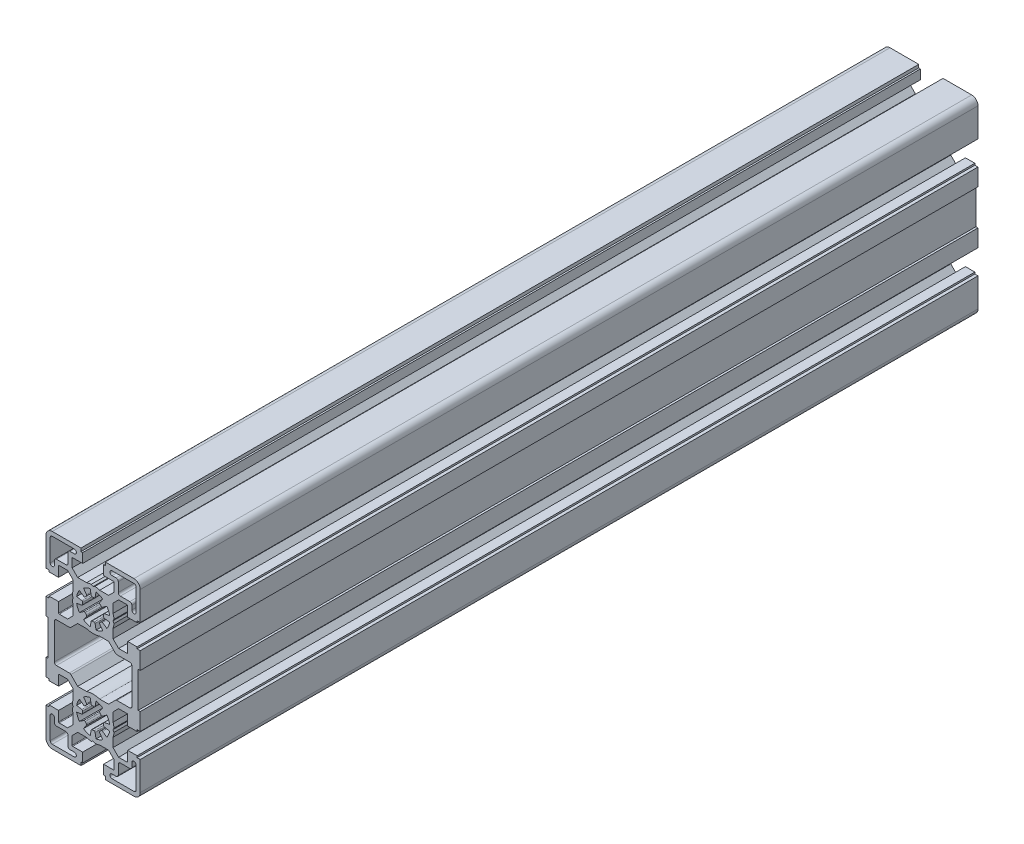
from build123d import *

# Parameters (mm, degrees)
EXTRUDE_1_DEPTH = 400


with BuildPart() as part:
    # Эскиз1 → Бобышка-Вытянуть1 (new body)
    with BuildSketch(Plane.XY):
        with BuildLine():
            Line((16.5, 27.5), (21, 27.5))
            Line((21, 27.5), (21, 28.299999))
            Line((21, 28.299999), (22.5, 28.299999))
            Line((22.5, 28.299999), (22.5, 42))
            ThreePointArc((22.5, 42), (21.621320344, 44.121320344), (19.5, 45))
            Line((19.5, 45), (5.799999, 45))
            Line((5.799999, 45), (5.799999, 43.5))
            Line((5.799999, 43.5), (5, 43.5))
            Line((5, 43.5), (5, 39))
            Line((5, 39), (9.75, 39))
            ThreePointArc((9.75, 39), (9.962132034, 38.912132034), (10.05, 38.7))
            Line((10.05, 38.7), (10.05, 34.671320344))
            Line((10.05, 34.671320344), (7.378679656, 32))
            Line((7.378679656, 32), (3.122498999, 32))
            ThreePointArc((3.122498999, 32), (2.007620973, 32.296400259), (0.866025404, 32.462429423))
            Line((0.866025404, 32.462429423), (0, 31.962429423))
            Line((0, 31.962429423), (-0.866025404, 32.462429423))
            ThreePointArc((-0.866025404, 32.462429423), (-2.007620973, 32.296400259), (-3.122498999, 32))
            Line((-3.122498999, 32), (-7.378679656, 32))
            Line((-7.378679656, 32), (-10.049999, 34.671319344))
            Line((-10.049999, 34.671319344), (-10.049999, 38.7))
            ThreePointArc((-10.049999, 38.7), (-9.962131034, 38.912132034), (-9.749999, 39))
            Line((-9.749999, 39), (-5, 39))
            Line((-5, 39), (-5, 43.5))
            Line((-5, 43.5), (-5.799999, 43.5))
            Line((-5.799999, 43.5), (-5.799999, 45))
            Line((-5.799999, 45), (-19.5, 45))
            ThreePointArc((-19.5, 45), (-21.621320344, 44.121320344), (-22.5, 42))
            Line((-22.5, 42), (-22.5, 28.299999))
            Line((-22.5, 28.299999), (-21, 28.299999))
            Line((-21, 28.299999), (-21, 27.5))
            Line((-21, 27.5), (-16.5, 27.5))
            Line((-16.5, 27.5), (-16.5, 32.249999))
            ThreePointArc((-16.5, 32.249999), (-16.412132034, 32.462131034), (-16.2, 32.549999))
            Line((-16.2, 32.549999), (-12.171319344, 32.549999))
            Line((-12.171319344, 32.549999), (-9.5, 29.878679656))
            Line((-9.5, 29.878679656), (-9.5, 25.622498999))
            ThreePointArc((-9.5, 25.622498999), (-9.796400259, 24.507620973), (-9.962429423, 23.366025404))
            Line((-9.962429423, 23.366025404), (-9.462429423, 22.5))
            Line((-9.462429423, 22.5), (-9.962429423, 21.633974596))
            ThreePointArc((-9.962429423, 21.633974596), (-9.796400259, 20.492379027), (-9.5, 19.377501001))
            Line((-9.5, 19.377501001), (-9.5, 15.121320344))
            Line((-9.5, 15.121320344), (-12.171320344, 12.45))
            Line((-12.171320344, 12.45), (-16.2, 12.45))
            ThreePointArc((-16.2, 12.45), (-16.412132034, 12.537867966), (-16.5, 12.75))
            Line((-16.5, 12.75), (-16.5, 17.5))
            Line((-16.5, 17.5), (-21, 17.5))
            Line((-21, 17.5), (-21, 16.700001))
            Line((-21, 16.700001), (-22.5, 16.700001))
            Line((-22.5, 16.700001), (-22.5, 8.5))
            Line((-22.5, 8.5), (-21.5, 8.5))
            Line((-21.5, 8.5), (-21.5, -8.5))
            Line((-21.5, -8.5), (-22.5, -8.5))
            Line((-22.5, -8.5), (-22.5, -16.700001))
            Line((-22.5, -16.700001), (-21, -16.700001))
            Line((-21, -16.700001), (-21, -17.5))
            Line((-21, -17.5), (-16.5, -17.5))
            Line((-16.5, -17.5), (-16.5, -12.75))
            ThreePointArc((-16.5, -12.75), (-16.412132034, -12.537867966), (-16.2, -12.45))
            Line((-16.2, -12.45), (-12.171320344, -12.45))
            Line((-12.171320344, -12.45), (-9.5, -15.121320344))
            Line((-9.5, -15.121320344), (-9.5, -19.377501001))
            ThreePointArc((-9.5, -19.377501001), (-9.796400259, -20.492379027), (-9.962429423, -21.633974596))
            Line((-9.962429423, -21.633974596), (-9.462429423, -22.5))
            Line((-9.462429423, -22.5), (-9.962429423, -23.366025404))
            ThreePointArc((-9.962429423, -23.366025404), (-9.796400259, -24.507620973), (-9.5, -25.622498999))
            Line((-9.5, -25.622498999), (-9.5, -29.878679656))
            Line((-9.5, -29.878679656), (-12.171319344, -32.549999))
            Line((-12.171319344, -32.549999), (-16.2, -32.549999))
            ThreePointArc((-16.2, -32.549999), (-16.412132034, -32.462131034), (-16.5, -32.249999))
            Line((-16.5, -32.249999), (-16.5, -27.5))
            Line((-16.5, -27.5), (-21, -27.5))
            Line((-21, -27.5), (-21, -28.299999))
            Line((-21, -28.299999), (-22.5, -28.299999))
            Line((-22.5, -28.299999), (-22.5, -42))
            ThreePointArc((-22.5, -42), (-21.621320344, -44.121320344), (-19.5, -45))
            Line((-19.5, -45), (-5.799999, -45))
            Line((-5.799999, -45), (-5.799999, -43.5))
            Line((-5.799999, -43.5), (-5, -43.5))
            Line((-5, -43.5), (-5, -39))
            Line((-5, -39), (-9.749999, -39))
            ThreePointArc((-9.749999, -39), (-9.962131034, -38.912132034), (-10.049999, -38.7))
            Line((-10.049999, -38.7), (-10.049999, -34.671319344))
            Line((-10.049999, -34.671319344), (-7.378679656, -32))
            Line((-7.378679656, -32), (-3.122498999, -32))
            ThreePointArc((-3.122498999, -32), (-2.007620973, -32.296400259), (-0.866025404, -32.462429423))
            Line((-0.866025404, -32.462429423), (0, -31.962429423))
            Line((0, -31.962429423), (0.866025404, -32.462429423))
            ThreePointArc((0.866025404, -32.462429423), (2.007620973, -32.296400259), (3.122498999, -32))
            Line((3.122498999, -32), (7.378679656, -32))
            Line((7.378679656, -32), (10.05, -34.671320344))
            Line((10.05, -34.671320344), (10.05, -38.7))
            ThreePointArc((10.05, -38.7), (9.962132034, -38.912132034), (9.75, -39))
            Line((9.75, -39), (5, -39))
            Line((5, -39), (5, -43.5))
            Line((5, -43.5), (5.799999, -43.5))
            Line((5.799999, -43.5), (5.799999, -45))
            Line((5.799999, -45), (19.5, -45))
            ThreePointArc((19.5, -45), (21.621320344, -44.121320344), (22.5, -42))
            Line((22.5, -42), (22.5, -28.299999))
            Line((22.5, -28.299999), (21, -28.299999))
            Line((21, -28.299999), (21, -27.5))
            Line((21, -27.5), (16.5, -27.5))
            Line((16.5, -27.5), (16.5, -32.249999))
            ThreePointArc((16.5, -32.249999), (16.412132034, -32.462131034), (16.2, -32.549999))
            Line((16.2, -32.549999), (12.171319344, -32.549999))
            Line((12.171319344, -32.549999), (9.5, -29.878679656))
            Line((9.5, -29.878679656), (9.5, -25.622498999))
            ThreePointArc((9.5, -25.622498999), (9.796400259, -24.507620973), (9.962429423, -23.366025404))
            Line((9.962429423, -23.366025404), (9.462429423, -22.5))
            Line((9.462429423, -22.5), (9.962429423, -21.633974596))
            ThreePointArc((9.962429423, -21.633974596), (9.796400259, -20.492379027), (9.5, -19.377501001))
            Line((9.5, -19.377501001), (9.5, -15.121320344))
            Line((9.5, -15.121320344), (12.171320344, -12.45))
            Line((12.171320344, -12.45), (16.2, -12.45))
            ThreePointArc((16.2, -12.45), (16.412132034, -12.537867966), (16.5, -12.75))
            Line((16.5, -12.75), (16.5, -17.5))
            Line((16.5, -17.5), (21, -17.5))
            Line((21, -17.5), (21, -16.700001))
            Line((21, -16.700001), (22.5, -16.700001))
            Line((22.5, -16.700001), (22.5, -8.5))
            Line((22.5, -8.5), (21.5, -8.5))
            Line((21.5, -8.5), (21.5, 8.5))
            Line((21.5, 8.5), (22.5, 8.5))
            Line((22.5, 8.5), (22.5, 16.700001))
            Line((22.5, 16.700001), (21, 16.700001))
            Line((21, 16.700001), (21, 17.5))
            Line((21, 17.5), (16.5, 17.5))
            Line((16.5, 17.5), (16.5, 12.75))
            ThreePointArc((16.5, 12.75), (16.412132034, 12.537867966), (16.2, 12.45))
            Line((16.2, 12.45), (12.171320344, 12.45))
            Line((12.171320344, 12.45), (9.5, 15.121320344))
            Line((9.5, 15.121320344), (9.5, 19.377501001))
            ThreePointArc((9.5, 19.377501001), (9.796400259, 20.492379027), (9.962429423, 21.633974596))
            Line((9.962429423, 21.633974596), (9.462429423, 22.5))
            Line((9.462429423, 22.5), (9.962429423, 23.366025404))
            ThreePointArc((9.962429423, 23.366025404), (9.796400259, 24.507620973), (9.5, 25.622498999))
            Line((9.5, 25.622498999), (9.5, 29.878679656))
            Line((9.5, 29.878679656), (12.171319344, 32.549999))
            Line((12.171319344, 32.549999), (16.2, 32.549999))
            ThreePointArc((16.2, 32.549999), (16.412132034, 32.462131034), (16.5, 32.249999))
            Line((16.5, 32.249999), (16.5, 27.5))
        make_face()
        with BuildLine():
            Line((-0.951109584, 27.894014463), (-1.38918508, 30.378462452))
            ThreePointArc((-1.38918508, 30.378462452), (-3.061467429, 29.891036664), (-4.588611737, 29.053216624))
            Line((-4.588611737, 29.053216624), (-3.14160736, 26.986680308))
            ThreePointArc((-3.14160736, 26.986680308), (-3.055338858, 26.635563126), (-3.228348507, 26.31808369))
            ThreePointArc((-3.228348507, 26.31808369), (-3.535533704, 26.035533704), (-3.81808369, 25.728348507))
            ThreePointArc((-3.81808369, 25.728348507), (-4.135563126, 25.555338858), (-4.486680308, 25.64160736))
            Line((-4.486680308, 25.64160736), (-6.553216624, 27.088611737))
            ThreePointArc((-6.553216624, 27.088611737), (-7.391036664, 25.561467429), (-7.878462452, 23.88918508))
            Line((-7.878462452, 23.88918508), (-5.394014463, 23.451109584))
            ThreePointArc((-5.394014463, 23.451109584), (-5.084736142, 23.263833295), (-4.982580573, 22.917005199))
            ThreePointArc((-4.982580573, 22.917005199), (-5.000000251, 22.5), (-4.982580573, 22.082994801))
            ThreePointArc((-4.982580573, 22.082994801), (-5.084736142, 21.736166705), (-5.394014463, 21.548890416))
            Line((-5.394014463, 21.548890416), (-7.878461766, 21.110815041))
            ThreePointArc((-7.878461766, 21.110815041), (-7.391036076, 19.43853297), (-6.553216219, 17.911388898))
            Line((-6.553216219, 17.911388898), (-4.486680308, 19.35839264))
            ThreePointArc((-4.486680308, 19.35839264), (-4.135563126, 19.444661142), (-3.81808369, 19.271651493))
            ThreePointArc((-3.81808369, 19.271651493), (-3.535533733, 18.964466325), (-3.22834857, 18.681916364))
            ThreePointArc((-3.22834857, 18.681916364), (-3.055338921, 18.364436882), (-3.141607485, 18.013319673))
            Line((-3.141607485, 18.013319673), (-4.588611972, 15.94678404))
            ThreePointArc((-4.588611972, 15.94678404), (-3.061467529, 15.10896382), (-1.38918499, 14.621537948))
            Line((-1.38918499, 14.621537948), (-0.951109584, 17.105985537))
            ThreePointArc((-0.951109584, 17.105985537), (-0.763833295, 17.415263858), (-0.417005199, 17.517419427))
            ThreePointArc((-0.417005199, 17.517419427), (0, 17.499999749), (0.417005199, 17.517419427))
            ThreePointArc((0.417005199, 17.517419427), (0.763833295, 17.415263858), (0.951109584, 17.105985537))
            Line((0.951109584, 17.105985537), (1.389184959, 14.621538234))
            ThreePointArc((1.389184959, 14.621538234), (3.061467283, 15.108964029), (4.58861155, 15.946784095))
            Line((4.58861155, 15.946784095), (3.141607485, 18.013319673))
            ThreePointArc((3.141607485, 18.013319673), (3.055338921, 18.364436882), (3.22834857, 18.681916364))
            ThreePointArc((3.22834857, 18.681916364), (3.535533704, 18.964466296), (3.818083636, 19.27165143))
            ThreePointArc((3.818083636, 19.27165143), (4.135563118, 19.444661079), (4.486680327, 19.358392515))
            Line((4.486680327, 19.358392515), (6.55321596, 17.911388028))
            ThreePointArc((6.55321596, 17.911388028), (7.39103618, 19.438532471), (7.878462052, 21.11081501))
            Line((7.878462052, 21.11081501), (5.394014463, 21.548890416))
            ThreePointArc((5.394014463, 21.548890416), (5.084736142, 21.736166705), (4.982580573, 22.082994801))
            ThreePointArc((4.982580573, 22.082994801), (5.000000251, 22.5), (4.982580573, 22.917005199))
            ThreePointArc((4.982580573, 22.917005199), (5.084736142, 23.263833295), (5.394014463, 23.451109584))
            Line((5.394014463, 23.451109584), (7.878462049, 23.889185009))
            ThreePointArc((7.878462049, 23.889185009), (7.391036176, 25.561467538), (6.55321596, 27.088611972))
            Line((6.55321596, 27.088611972), (4.486680327, 25.641607485))
            ThreePointArc((4.486680327, 25.641607485), (4.135563118, 25.555338921), (3.818083636, 25.72834857))
            ThreePointArc((3.818083636, 25.72834857), (3.535533675, 26.035533733), (3.228348507, 26.31808369))
            ThreePointArc((3.228348507, 26.31808369), (3.055338858, 26.635563126), (3.14160736, 26.986680308))
            Line((3.14160736, 26.986680308), (4.588611737, 29.053216624))
            ThreePointArc((4.588611737, 29.053216624), (3.061467429, 29.891036664), (1.38918508, 30.378462452))
            Line((1.38918508, 30.378462452), (0.951109584, 27.894014463))
            ThreePointArc((0.951109584, 27.894014463), (0.763833295, 27.584736142), (0.417005199, 27.482580573))
            ThreePointArc((0.417005199, 27.482580573), (0, 27.500000251), (-0.417005199, 27.482580573))
            ThreePointArc((-0.417005199, 27.482580573), (-0.763833295, 27.584736142), (-0.951109584, 27.894014463))
        make_face(mode=Mode.SUBTRACT)
        with BuildLine():
            Line((-17.5, 34.5), (-13, 34.5))
            ThreePointArc((-13, 34.5), (-12.292894344, 34.792894094), (-12.000002, 35.500000474))
            Line((-12.000002, 35.500000474), (-12, 40))
            ThreePointArc((-12, 40), (-11.707106781, 40.707106781), (-11, 41))
            Line((-11, 41), (-9, 41))
            ThreePointArc((-9, 41), (-8, 42), (-9, 43))
            Line((-9, 43), (-19.5, 43))
            ThreePointArc((-19.5, 43), (-20.207106781, 42.707106781), (-20.5, 42))
            Line((-20.5, 42), (-20.5, 31.5))
            ThreePointArc((-20.5, 31.5), (-19.5, 30.5), (-18.5, 31.5))
            Line((-18.5, 31.5), (-18.5, 33.5))
            ThreePointArc((-18.5, 33.5), (-18.207106781, 34.207106781), (-17.5, 34.5))
        make_face(mode=Mode.SUBTRACT)
        with BuildLine():
            Line((-7.378679656, 13), (-3.122498999, 13))
            ThreePointArc((-3.122498999, 13), (0, 12.5), (3.122498999, 13))
            Line((3.122498999, 13), (7.378679656, 13))
            Line((7.378679656, 13), (10.635786438, 9.742893219))
            ThreePointArc((10.635786438, 9.742893219), (10.960209786, 9.526120467), (11.342893219, 9.45))
            Line((11.342893219, 9.45), (17.5, 9.45))
            ThreePointArc((17.5, 9.45), (18.207106781, 9.157106781), (18.5, 8.45))
            Line((18.5, 8.45), (18.5, -8.45))
            ThreePointArc((18.5, -8.45), (18.207106781, -9.157106781), (17.5, -9.45))
            Line((17.5, -9.45), (11.342893219, -9.45))
            ThreePointArc((11.342893219, -9.45), (10.960209786, -9.526120467), (10.635786438, -9.742893219))
            Line((10.635786438, -9.742893219), (7.378679656, -13))
            Line((7.378679656, -13), (3.122498999, -13))
            ThreePointArc((3.122498999, -13), (0, -12.5), (-3.122498999, -13))
            Line((-3.122498999, -13), (-7.378679656, -13))
            Line((-7.378679656, -13), (-10.635786438, -9.742893219))
            ThreePointArc((-10.635786438, -9.742893219), (-10.960209786, -9.526120467), (-11.342893219, -9.45))
            Line((-11.342893219, -9.45), (-17.5, -9.45))
            ThreePointArc((-17.5, -9.45), (-18.207106781, -9.157106781), (-18.5, -8.45))
            Line((-18.5, -8.45), (-18.5, 8.45))
            ThreePointArc((-18.5, 8.45), (-18.207106781, 9.157106781), (-17.5, 9.45))
            Line((-17.5, 9.45), (-11.342893219, 9.45))
            ThreePointArc((-11.342893219, 9.45), (-10.960209786, 9.526120467), (-10.635786438, 9.742893219))
            Line((-10.635786438, 9.742893219), (-7.378679656, 13))
        make_face(mode=Mode.SUBTRACT)
        with BuildLine():
            Line((17.5, 34.5), (13.000000474, 34.500002))
            ThreePointArc((13.000000474, 34.500002), (12.292894094, 34.792894344), (12, 35.5))
            Line((12, 35.5), (12, 40))
            ThreePointArc((12, 40), (11.707106781, 40.707106781), (11, 41))
            Line((11, 41), (9, 41))
            ThreePointArc((9, 41), (8, 42), (9, 43))
            Line((9, 43), (19.5, 43))
            ThreePointArc((19.5, 43), (20.207106781, 42.707106781), (20.5, 42))
            Line((20.5, 42), (20.5, 31.5))
            ThreePointArc((20.5, 31.5), (19.5, 30.5), (18.5, 31.5))
            Line((18.5, 31.5), (18.5, 33.5))
            ThreePointArc((18.5, 33.5), (18.207106781, 34.207106781), (17.5, 34.5))
        make_face(mode=Mode.SUBTRACT)
        with BuildLine():
            Line((-0.951109584, -27.894014463), (-1.38918508, -30.378462452))
            ThreePointArc((-1.38918508, -30.378462452), (-3.061467429, -29.891036664), (-4.588611737, -29.053216624))
            Line((-4.588611737, -29.053216624), (-3.14160736, -26.986680308))
            ThreePointArc((-3.14160736, -26.986680308), (-3.055338858, -26.635563126), (-3.228348507, -26.31808369))
            ThreePointArc((-3.228348507, -26.31808369), (-3.535533704, -26.035533704), (-3.81808369, -25.728348507))
            ThreePointArc((-3.81808369, -25.728348507), (-4.135563126, -25.555338858), (-4.486680308, -25.64160736))
            Line((-4.486680308, -25.64160736), (-6.553216624, -27.088611737))
            ThreePointArc((-6.553216624, -27.088611737), (-7.391036664, -25.561467429), (-7.878462452, -23.88918508))
            Line((-7.878462452, -23.88918508), (-5.394014463, -23.451109584))
            ThreePointArc((-5.394014463, -23.451109584), (-5.084736142, -23.263833295), (-4.982580573, -22.917005199))
            ThreePointArc((-4.982580573, -22.917005199), (-5.000000251, -22.5), (-4.982580573, -22.082994801))
            ThreePointArc((-4.982580573, -22.082994801), (-5.084736142, -21.736166705), (-5.394014463, -21.548890416))
            Line((-5.394014463, -21.548890416), (-7.878462221, -21.110814981))
            ThreePointArc((-7.878462221, -21.110814981), (-7.391036449, -19.43853267), (-6.55321643, -17.911388399))
            Line((-6.55321643, -17.911388399), (-4.486680308, -19.35839264))
            ThreePointArc((-4.486680308, -19.35839264), (-4.135563126, -19.444661142), (-3.81808369, -19.271651493))
            ThreePointArc((-3.81808369, -19.271651493), (-3.535533733, -18.964466325), (-3.22834857, -18.681916364))
            ThreePointArc((-3.22834857, -18.681916364), (-3.055338921, -18.364436882), (-3.141607485, -18.013319673))
            Line((-3.141607485, -18.013319673), (-4.588611686, -15.946783901))
            ThreePointArc((-4.588611686, -15.946783901), (-3.061467374, -15.108963809), (-1.389185, -14.621538))
            Line((-1.389185, -14.621538), (-0.951109584, -17.105985537))
            ThreePointArc((-0.951109584, -17.105985537), (-0.763833295, -17.415263858), (-0.417005199, -17.517419427))
            ThreePointArc((-0.417005199, -17.517419427), (0, -17.499999749), (0.417005199, -17.517419427))
            ThreePointArc((0.417005199, -17.517419427), (0.763833295, -17.415263858), (0.951109584, -17.105985537))
            Line((0.951109584, -17.105985537), (1.389184948, -14.621538182))
            ThreePointArc((1.389184948, -14.621538182), (3.061467438, -15.10896404), (4.588611836, -15.946784235))
            Line((4.588611836, -15.946784235), (3.141607485, -18.013319673))
            ThreePointArc((3.141607485, -18.013319673), (3.055338921, -18.364436882), (3.22834857, -18.681916364))
            ThreePointArc((3.22834857, -18.681916364), (3.535533704, -18.964466296), (3.818083636, -19.27165143))
            ThreePointArc((3.818083636, -19.27165143), (4.135563118, -19.444661079), (4.486680327, -19.358392515))
            Line((4.486680327, -19.358392515), (6.553216099, -17.911388314))
            ThreePointArc((6.553216099, -17.911388314), (7.391036191, -19.438532626), (7.878462, -21.110815))
            Line((7.878462, -21.110815), (5.394014463, -21.548890416))
            ThreePointArc((5.394014463, -21.548890416), (5.084736142, -21.736166705), (4.982580573, -22.082994801))
            ThreePointArc((4.982580573, -22.082994801), (5.000000251, -22.5), (4.982580573, -22.917005199))
            ThreePointArc((4.982580573, -22.917005199), (5.084736142, -23.263833295), (5.394014463, -23.451109584))
            Line((5.394014463, -23.451109584), (7.878462049, -23.889185009))
            ThreePointArc((7.878462049, -23.889185009), (7.391036176, -25.561467538), (6.55321596, -27.088611972))
            Line((6.55321596, -27.088611972), (4.486680327, -25.641607485))
            ThreePointArc((4.486680327, -25.641607485), (4.135563118, -25.555338921), (3.818083636, -25.72834857))
            ThreePointArc((3.818083636, -25.72834857), (3.535533675, -26.035533733), (3.228348507, -26.31808369))
            ThreePointArc((3.228348507, -26.31808369), (3.055338858, -26.635563126), (3.14160736, -26.986680308))
            Line((3.14160736, -26.986680308), (4.588611737, -29.053216624))
            ThreePointArc((4.588611737, -29.053216624), (3.061467429, -29.891036664), (1.38918508, -30.378462452))
            Line((1.38918508, -30.378462452), (0.951109584, -27.894014463))
            ThreePointArc((0.951109584, -27.894014463), (0.763833295, -27.584736142), (0.417005199, -27.482580573))
            ThreePointArc((0.417005199, -27.482580573), (0, -27.500000251), (-0.417005199, -27.482580573))
            ThreePointArc((-0.417005199, -27.482580573), (-0.763833295, -27.584736142), (-0.951109584, -27.894014463))
        make_face(mode=Mode.SUBTRACT)
        with BuildLine():
            Line((-17.5, -34.5), (-13.000000474, -34.500002))
            ThreePointArc((-13.000000474, -34.500002), (-12.292894094, -34.792894344), (-12, -35.5))
            Line((-12, -35.5), (-12, -40))
            ThreePointArc((-12, -40), (-11.707106781, -40.707106781), (-11, -41))
            Line((-11, -41), (-9, -41))
            ThreePointArc((-9, -41), (-8, -42), (-9, -43))
            Line((-9, -43), (-19.5, -43))
            ThreePointArc((-19.5, -43), (-20.207106781, -42.707106781), (-20.5, -42))
            Line((-20.5, -42), (-20.5, -31.5))
            ThreePointArc((-20.5, -31.5), (-19.5, -30.5), (-18.5, -31.5))
            Line((-18.5, -31.5), (-18.5, -33.5))
            ThreePointArc((-18.5, -33.5), (-18.207106781, -34.207106781), (-17.5, -34.5))
        make_face(mode=Mode.SUBTRACT)
        with BuildLine():
            Line((17.5, -34.5), (13, -34.5))
            ThreePointArc((13, -34.5), (12.292894344, -34.792894094), (12.000002, -35.500000474))
            Line((12.000002, -35.500000474), (12, -40))
            ThreePointArc((12, -40), (11.707106781, -40.707106781), (11, -41))
            Line((11, -41), (9, -41))
            ThreePointArc((9, -41), (8, -42), (9, -43))
            Line((9, -43), (19.5, -43))
            ThreePointArc((19.5, -43), (20.207106781, -42.707106781), (20.5, -42))
            Line((20.5, -42), (20.5, -31.5))
            ThreePointArc((20.5, -31.5), (19.5, -30.5), (18.5, -31.5))
            Line((18.5, -31.5), (18.5, -33.5))
            ThreePointArc((18.5, -33.5), (18.207106781, -34.207106781), (17.5, -34.5))
        make_face(mode=Mode.SUBTRACT)
    extrude(amount=EXTRUDE_1_DEPTH)


solid = part.part
